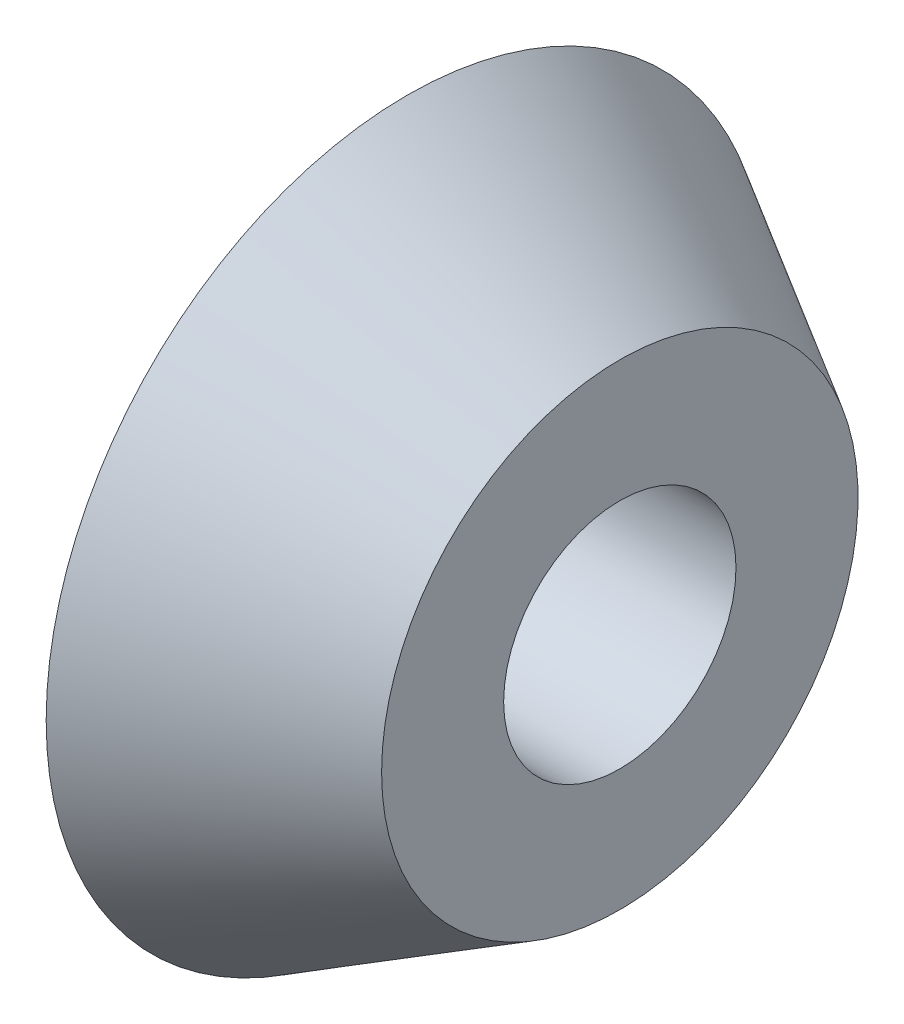
from build123d import *


with BuildPart() as part:
    # Sketch1 → Revolve1 (revolve)
    with BuildSketch(Plane.XY):
        Polygon((4.413209819, 8.0518), (25.50123014, 8.0518), (25.50123014, 16.51), (10.763209819, 25.019), (10.763209819, 16.51), (9.747209819, 15.494), (4.413209819, 15.494), align=None)
    revolve(axis=Axis((0, 0, 0), (1, 0, 0)))


solid = part.part
